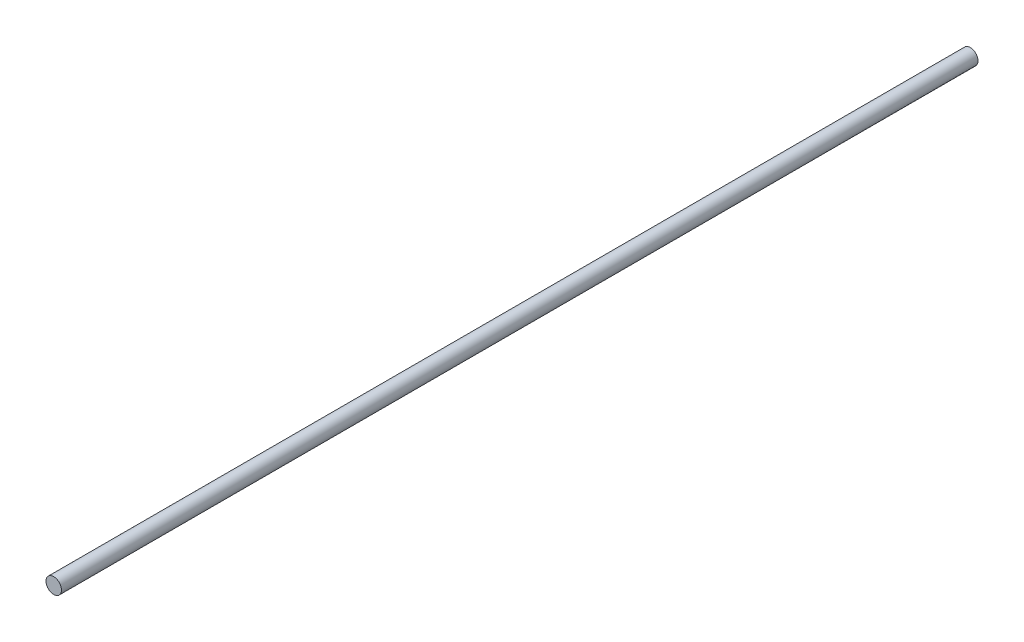
from build123d import *

# Parameters (mm, degrees)
SKETCH1_R           = 4.05
BOSS_EXTRUDE1_DEPTH = 480


with BuildPart() as part:
    # Sketch1 → Boss-Extrude1 (new body)
    with BuildSketch(Plane.XY):
        Circle(SKETCH1_R)
    extrude(amount=BOSS_EXTRUDE1_DEPTH)


solid = part.part
